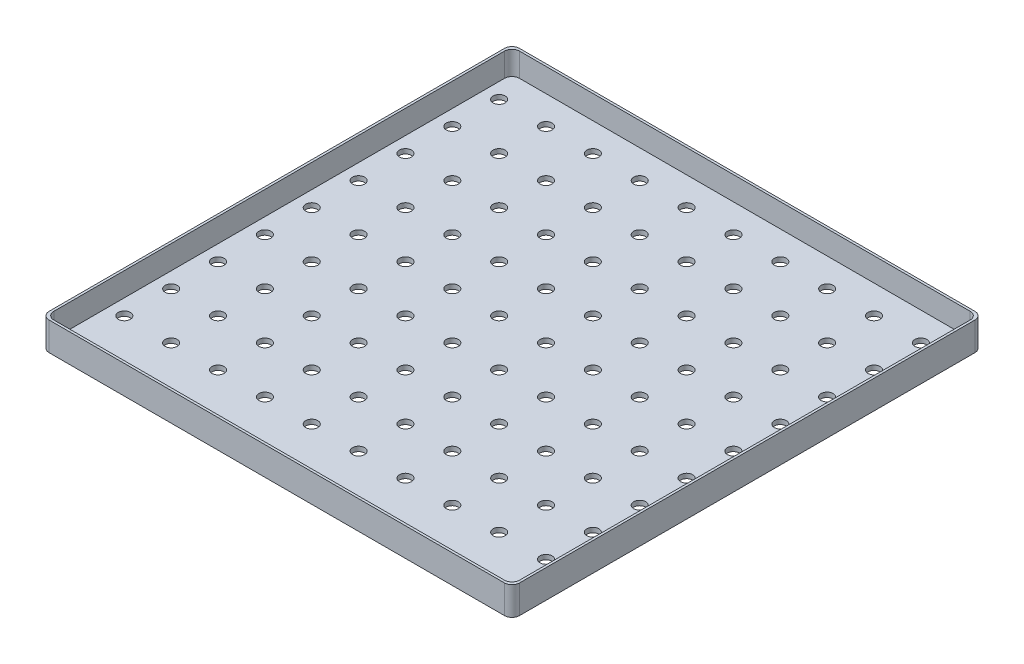
from build123d import *

# Parameters (mm, degrees)
SKETCH1_W           = 249
SKETCH1_H           = 249
BOSS_EXTRUDE1_DEPTH = 2.5
SKETCH2_W           = 249
SKETCH2_H           = 249
SKETCH2_W_2         = 246.5
SKETCH2_H_2         = 246.5
BOSS_EXTRUDE2_DEPTH = 12.5
FILLET1_R           = 4
FILLET2_R           = 4
SKETCH3_R           = 3.2
CUT_EXTRUDE1_DEPTH  = 12.5


with BuildPart() as part:
    # Sketch1 → Boss-Extrude1 (new body)
    with BuildSketch(Plane(origin=(0, 0, 0), x_dir=(1, 0, 0), z_dir=(0, 1, 0))):
        with Locations((-14.616719243, 12.723974763)):
            Rectangle(SKETCH1_W, SKETCH1_H)
    extrude(amount=BOSS_EXTRUDE1_DEPTH)

    # Sketch2 → Boss-Extrude2 (add)
    with BuildSketch(Plane(origin=(0, 2.5, 0), x_dir=(1, 0, 0), z_dir=(0, 1, 0))):
        with Locations((-14.616719243, 12.723974763)):
            Rectangle(SKETCH2_W, SKETCH2_H)
        with Locations((-14.616719243, 12.723974763)):
            Rectangle(SKETCH2_W_2, SKETCH2_H_2, mode=Mode.SUBTRACT)
    extrude(amount=BOSS_EXTRUDE2_DEPTH)

    # Fillet1
    fillet1_edges = [part.edges().sort_by_distance(p)[0] for p in [
        (-139.116719243, 7.5, -137.223974763),
        (109.883280757, 7.5, -137.223974763),
        (109.883280757, 7.5, 111.776025237),
        (-139.116719243, 7.5, 111.776025237),
    ]]
    fillet(fillet1_edges, radius=FILLET1_R)

    # Fillet2
    fillet2_edges = [part.edges().sort_by_distance(p)[0] for p in [
        (108.633280757, 8.75, -135.973974763),
        (-137.866719243, 8.75, -135.973974763),
        (-137.866719243, 8.75, 110.526025237),
        (108.633280757, 8.75, 110.526025237),
    ]]
    fillet(fillet2_edges, radius=FILLET2_R)

    # Sketch3 → Cut-Extrude1 (cut)
    with BuildSketch(Plane.XZ):
        with Locations((-129.616719243, 102.276025237)):
            Circle(SKETCH3_R)
        with Locations((-129.616719243, 77.476025237)):
            Circle(SKETCH3_R)
        with Locations((-129.616719243, 52.676025237)):
            Circle(SKETCH3_R)
        with Locations((-129.616719243, 27.876025237)):
            Circle(SKETCH3_R)
        with Locations((-129.616719243, 3.076025237)):
            Circle(SKETCH3_R)
        with Locations((-129.616719243, -21.723974763)):
            Circle(SKETCH3_R)
        with Locations((-129.616719243, -46.523974763)):
            Circle(SKETCH3_R)
        with Locations((-129.616719243, -71.323974763)):
            Circle(SKETCH3_R)
        with Locations((-129.616719243, -96.123974763)):
            Circle(SKETCH3_R)
        with Locations((-129.616719243, -120.923974763)):
            Circle(SKETCH3_R)
        with Locations((-104.816719243, 102.276025237)):
            Circle(SKETCH3_R)
        with Locations((-104.816719243, 77.476025237)):
            Circle(SKETCH3_R)
        with Locations((-104.816719243, 52.676025237)):
            Circle(SKETCH3_R)
        with Locations((-104.816719243, 27.876025237)):
            Circle(SKETCH3_R)
        with Locations((-104.816719243, 3.076025237)):
            Circle(SKETCH3_R)
        with Locations((-104.816719243, -21.723974763)):
            Circle(SKETCH3_R)
        with Locations((-104.816719243, -46.523974763)):
            Circle(SKETCH3_R)
        with Locations((-104.816719243, -71.323974763)):
            Circle(SKETCH3_R)
        with Locations((-104.816719243, -96.123974763)):
            Circle(SKETCH3_R)
        with Locations((-104.816719243, -120.923974763)):
            Circle(SKETCH3_R)
        with Locations((-80.016719243, 102.276025237)):
            Circle(SKETCH3_R)
        with Locations((-80.016719243, 77.476025237)):
            Circle(SKETCH3_R)
        with Locations((-80.016719243, 52.676025237)):
            Circle(SKETCH3_R)
        with Locations((-80.016719243, 27.876025237)):
            Circle(SKETCH3_R)
        with Locations((-80.016719243, 3.076025237)):
            Circle(SKETCH3_R)
        with Locations((-80.016719243, -21.723974763)):
            Circle(SKETCH3_R)
        with Locations((-80.016719243, -46.523974763)):
            Circle(SKETCH3_R)
        with Locations((-80.016719243, -71.323974763)):
            Circle(SKETCH3_R)
        with Locations((-80.016719243, -96.123974763)):
            Circle(SKETCH3_R)
        with Locations((-80.016719243, -120.923974763)):
            Circle(SKETCH3_R)
        with Locations((-55.216719243, 102.276025237)):
            Circle(SKETCH3_R)
        with Locations((-55.216719243, 77.476025237)):
            Circle(SKETCH3_R)
        with Locations((-55.216719243, 52.676025237)):
            Circle(SKETCH3_R)
        with Locations((-55.216719243, 27.876025237)):
            Circle(SKETCH3_R)
        with Locations((-55.216719243, 3.076025237)):
            Circle(SKETCH3_R)
        with Locations((-55.216719243, -21.723974763)):
            Circle(SKETCH3_R)
        with Locations((-55.216719243, -46.523974763)):
            Circle(SKETCH3_R)
        with Locations((-55.216719243, -71.323974763)):
            Circle(SKETCH3_R)
        with Locations((-55.216719243, -96.123974763)):
            Circle(SKETCH3_R)
        with Locations((-55.216719243, -120.923974763)):
            Circle(SKETCH3_R)
        with Locations((-30.416719243, 102.276025237)):
            Circle(SKETCH3_R)
        with Locations((-30.416719243, 77.476025237)):
            Circle(SKETCH3_R)
        with Locations((-30.416719243, 52.676025237)):
            Circle(SKETCH3_R)
        with Locations((-30.416719243, 27.876025237)):
            Circle(SKETCH3_R)
        with Locations((-30.416719243, 3.076025237)):
            Circle(SKETCH3_R)
        with Locations((-30.416719243, -21.723974763)):
            Circle(SKETCH3_R)
        with Locations((-30.416719243, -46.523974763)):
            Circle(SKETCH3_R)
        with Locations((-30.416719243, -71.323974763)):
            Circle(SKETCH3_R)
        with Locations((-30.416719243, -96.123974763)):
            Circle(SKETCH3_R)
        with Locations((-30.416719243, -120.923974763)):
            Circle(SKETCH3_R)
        with Locations((-5.616719243, 102.276025237)):
            Circle(SKETCH3_R)
        with Locations((-5.616719243, 77.476025237)):
            Circle(SKETCH3_R)
        with Locations((-5.616719243, 52.676025237)):
            Circle(SKETCH3_R)
        with Locations((-5.616719243, 27.876025237)):
            Circle(SKETCH3_R)
        with Locations((-5.616719243, 3.076025237)):
            Circle(SKETCH3_R)
        with Locations((-5.616719243, -21.723974763)):
            Circle(SKETCH3_R)
        with Locations((-5.616719243, -46.523974763)):
            Circle(SKETCH3_R)
        with Locations((-5.616719243, -71.323974763)):
            Circle(SKETCH3_R)
        with Locations((-5.616719243, -96.123974763)):
            Circle(SKETCH3_R)
        with Locations((-5.616719243, -120.923974763)):
            Circle(SKETCH3_R)
        with Locations((19.183280757, 102.276025237)):
            Circle(SKETCH3_R)
        with Locations((19.183280757, 77.476025237)):
            Circle(SKETCH3_R)
        with Locations((19.183280757, 52.676025237)):
            Circle(SKETCH3_R)
        with Locations((19.183280757, 27.876025237)):
            Circle(SKETCH3_R)
        with Locations((19.183280757, 3.076025237)):
            Circle(SKETCH3_R)
        with Locations((19.183280757, -21.723974763)):
            Circle(SKETCH3_R)
        with Locations((19.183280757, -46.523974763)):
            Circle(SKETCH3_R)
        with Locations((19.183280757, -71.323974763)):
            Circle(SKETCH3_R)
        with Locations((19.183280757, -96.123974763)):
            Circle(SKETCH3_R)
        with Locations((19.183280757, -120.923974763)):
            Circle(SKETCH3_R)
        with Locations((43.983280757, 102.276025237)):
            Circle(SKETCH3_R)
        with Locations((43.983280757, 77.476025237)):
            Circle(SKETCH3_R)
        with Locations((43.983280757, 52.676025237)):
            Circle(SKETCH3_R)
        with Locations((43.983280757, 27.876025237)):
            Circle(SKETCH3_R)
        with Locations((43.983280757, 3.076025237)):
            Circle(SKETCH3_R)
        with Locations((43.983280757, -21.723974763)):
            Circle(SKETCH3_R)
        with Locations((43.983280757, -46.523974763)):
            Circle(SKETCH3_R)
        with Locations((43.983280757, -71.323974763)):
            Circle(SKETCH3_R)
        with Locations((43.983280757, -96.123974763)):
            Circle(SKETCH3_R)
        with Locations((43.983280757, -120.923974763)):
            Circle(SKETCH3_R)
        with Locations((68.783280757, 102.276025237)):
            Circle(SKETCH3_R)
        with Locations((68.783280757, 77.476025237)):
            Circle(SKETCH3_R)
        with Locations((68.783280757, 52.676025237)):
            Circle(SKETCH3_R)
        with Locations((68.783280757, 27.876025237)):
            Circle(SKETCH3_R)
        with Locations((68.783280757, 3.076025237)):
            Circle(SKETCH3_R)
        with Locations((68.783280757, -21.723974763)):
            Circle(SKETCH3_R)
        with Locations((68.783280757, -46.523974763)):
            Circle(SKETCH3_R)
        with Locations((68.783280757, -71.323974763)):
            Circle(SKETCH3_R)
        with Locations((68.783280757, -96.123974763)):
            Circle(SKETCH3_R)
        with Locations((68.783280757, -120.923974763)):
            Circle(SKETCH3_R)
        with Locations((93.583280757, 102.276025237)):
            Circle(SKETCH3_R)
        with Locations((93.583280757, 77.476025237)):
            Circle(SKETCH3_R)
        with Locations((93.583280757, 52.676025237)):
            Circle(SKETCH3_R)
        with Locations((93.583280757, 27.876025237)):
            Circle(SKETCH3_R)
        with Locations((93.583280757, 3.076025237)):
            Circle(SKETCH3_R)
        with Locations((93.583280757, -21.723974763)):
            Circle(SKETCH3_R)
        with Locations((93.583280757, -46.523974763)):
            Circle(SKETCH3_R)
        with Locations((93.583280757, -71.323974763)):
            Circle(SKETCH3_R)
        with Locations((93.583280757, -96.123974763)):
            Circle(SKETCH3_R)
        with Locations((93.583280757, -120.923974763)):
            Circle(SKETCH3_R)
    extrude(amount=-CUT_EXTRUDE1_DEPTH, mode=Mode.SUBTRACT)


solid = part.part
